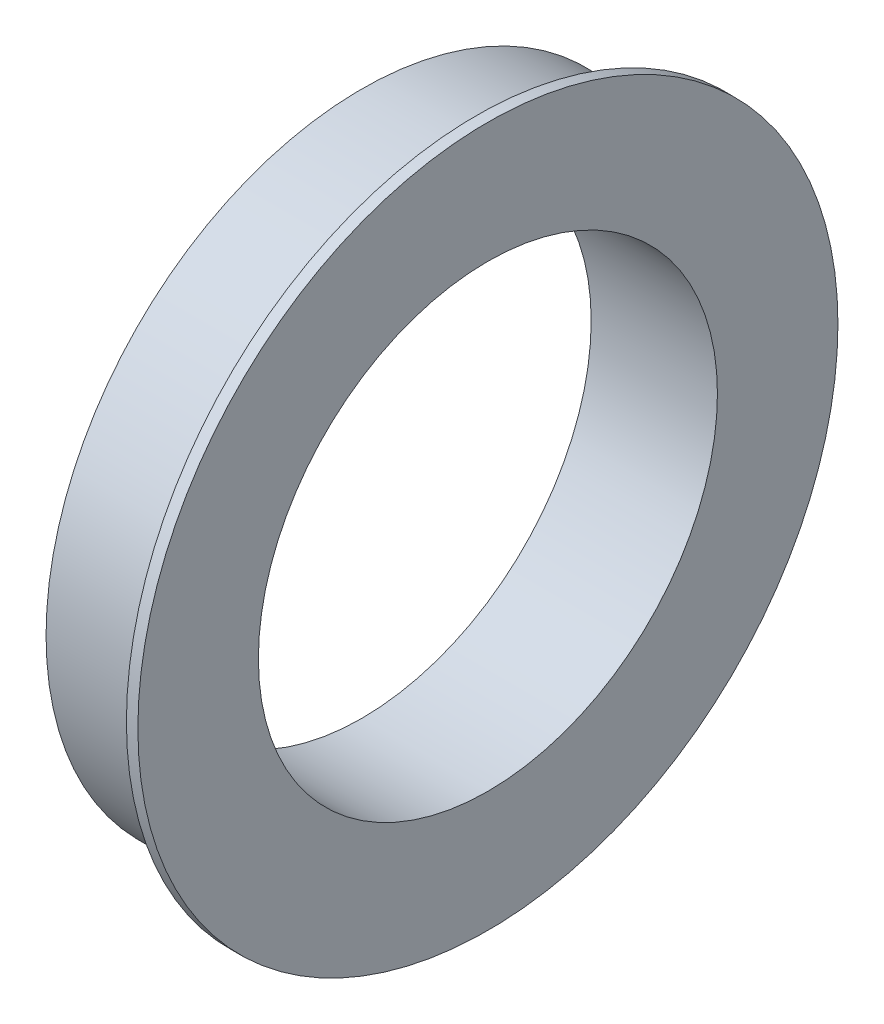
from build123d import *


with BuildPart() as part:
    # Sketch1 → Revolve1 (revolve)
    with BuildSketch(Plane.XY):
        Polygon((0, 40), (22, 40), (22, 61), (20, 61), (20, 55), (0, 55), align=None)
    revolve(axis=Axis((0, 0, 0), (1, 0, 0)))


solid = part.part
